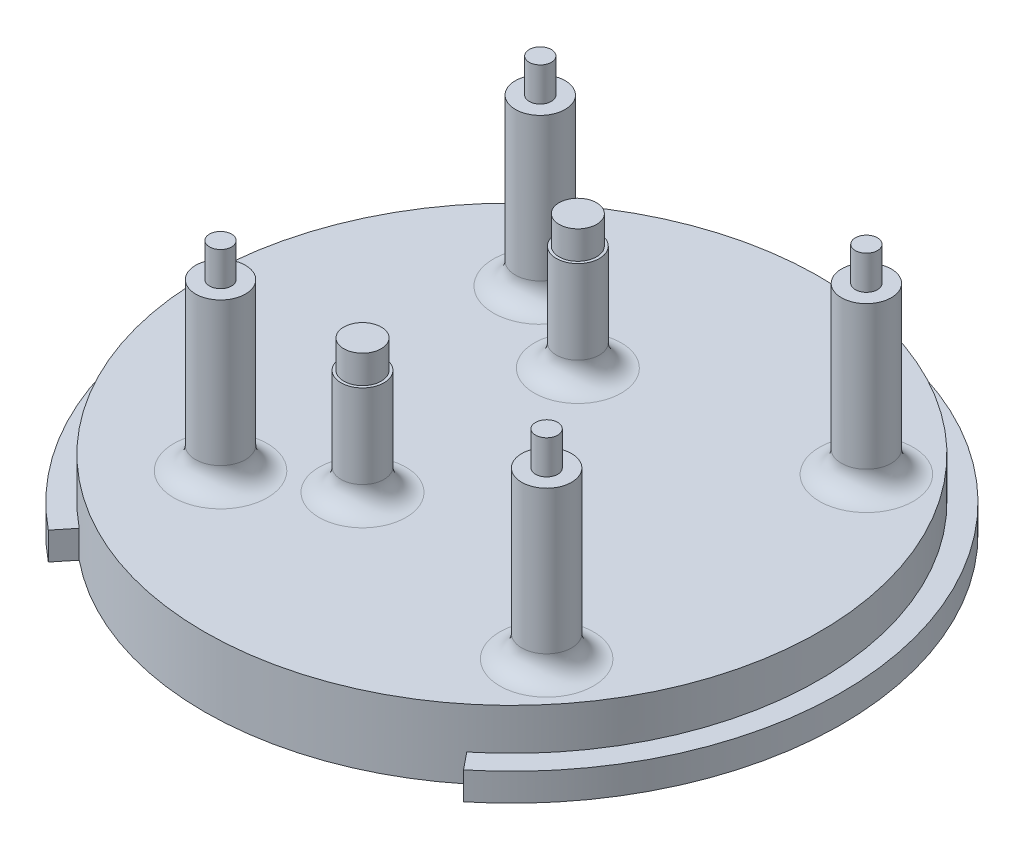
from build123d import *

# Parameters (mm, degrees)
SKETCH1_R           = 23.8125
BOSS_EXTRUDE1_DEPTH = 2
SKETCH2_R           = 22.225
BOSS_EXTRUDE2_DEPTH = 3
CUT_EXTRUDE2_DEPTH  = 3
SKETCH6_R           = 1.8
BOSS_EXTRUDE3_DEPTH = 11.95
SKETCH7_R           = 1.55575
BOSS_EXTRUDE4_DEPTH = 7.632
SKETCH8_R           = 0.8
BOSS_EXTRUDE5_DEPTH = 2.45
SKETCH9_R           = 1.35575
BOSS_EXTRUDE6_DEPTH = 2.032
FILLET1_R           = 1.5875


with BuildPart() as part:
    # Sketch1 → Boss-Extrude1 (new body)
    with BuildSketch(Plane(origin=(0, 0, 0), x_dir=(1, 0, 0), z_dir=(0, 1, 0))):
        Circle(SKETCH1_R)
    extrude(amount=BOSS_EXTRUDE1_DEPTH)

    # Sketch2 → Boss-Extrude2 (add)
    with BuildSketch(Plane(origin=(0, 2, 0), x_dir=(1, 0, 0), z_dir=(0, 1, 0))):
        Circle(SKETCH2_R)
    extrude(amount=BOSS_EXTRUDE2_DEPTH)

    # Sketch4 → Cut-Extrude2 (cut, through all)
    with BuildSketch(Plane(origin=(0, 2, 0), x_dir=(1, 0, 0), z_dir=(0, 1, 0))):
        with BuildLine():
            Line((-15, -18.494192501), (-14, -17.261246334))
            ThreePointArc((-14, -17.261246334), (0, -22.225), (14, -17.261246334))
            Line((14, -17.261246334), (15, -18.494192501))
            ThreePointArc((15, -18.494192501), (0, -23.8125), (-15, -18.494192501))
        make_face()
    extrude(amount=-CUT_EXTRUDE2_DEPTH, mode=Mode.SUBTRACT)

    # Sketch6 → Boss-Extrude3 (add)
    with BuildSketch(Plane(origin=(0, 5, 0), x_dir=(1, 0, 0), z_dir=(0, 1, 0))):
        with Locations((-9.5, 11.55)):
            Circle(SKETCH6_R)
        with Locations((-9.5, -11.55)):
            Circle(SKETCH6_R)
        with Locations((14.06, -11.55)):
            Circle(SKETCH6_R)
        with Locations((14.06, 11.55)):
            Circle(SKETCH6_R)
    extrude(amount=BOSS_EXTRUDE3_DEPTH)

    # Sketch7 → Boss-Extrude4 (add)
    with BuildSketch(Plane(origin=(0, 5, 0), x_dir=(1, 0, 0), z_dir=(0, 1, 0))):
        with Locations((-3.01475, -7.77875)):
            Circle(SKETCH7_R)
        with Locations((-3.01475, 7.77875)):
            Circle(SKETCH7_R)
    extrude(amount=BOSS_EXTRUDE4_DEPTH)

    # Sketch8 → Boss-Extrude5 (add)
    with BuildSketch(Plane(origin=(0, 16.95, 0), x_dir=(1, 0, 0), z_dir=(0, 1, 0))):
        with Locations((-9.5, 11.55)):
            Circle(SKETCH8_R)
        with Locations((-9.5, -11.55)):
            Circle(SKETCH8_R)
        with Locations((14.06, -11.55)):
            Circle(SKETCH8_R)
        with Locations((14.06, 11.55)):
            Circle(SKETCH8_R)
    extrude(amount=BOSS_EXTRUDE5_DEPTH)

    # Sketch9 → Boss-Extrude6 (add)
    with BuildSketch(Plane(origin=(0, 12.632, 0), x_dir=(1, 0, 0), z_dir=(0, 1, 0))):
        with Locations((-3.01475, 7.77875)):
            Circle(SKETCH9_R)
        with Locations((-3.01475, -7.77875)):
            Circle(SKETCH9_R)
    extrude(amount=BOSS_EXTRUDE6_DEPTH)

    # Fillet1
    fillet1_edges = [part.edges().sort_by_distance(p)[0] for p in [
        (-11.3, 5, -11.55),
        (-11.3, 5, 11.55),
        (12.26, 5, 11.55),
        (12.26, 5, -11.55),
        (-4.5705, 5, 7.77875),
        (-4.5705, 5, -7.77875),
    ]]
    fillet(fillet1_edges, radius=FILLET1_R)


solid = part.part
